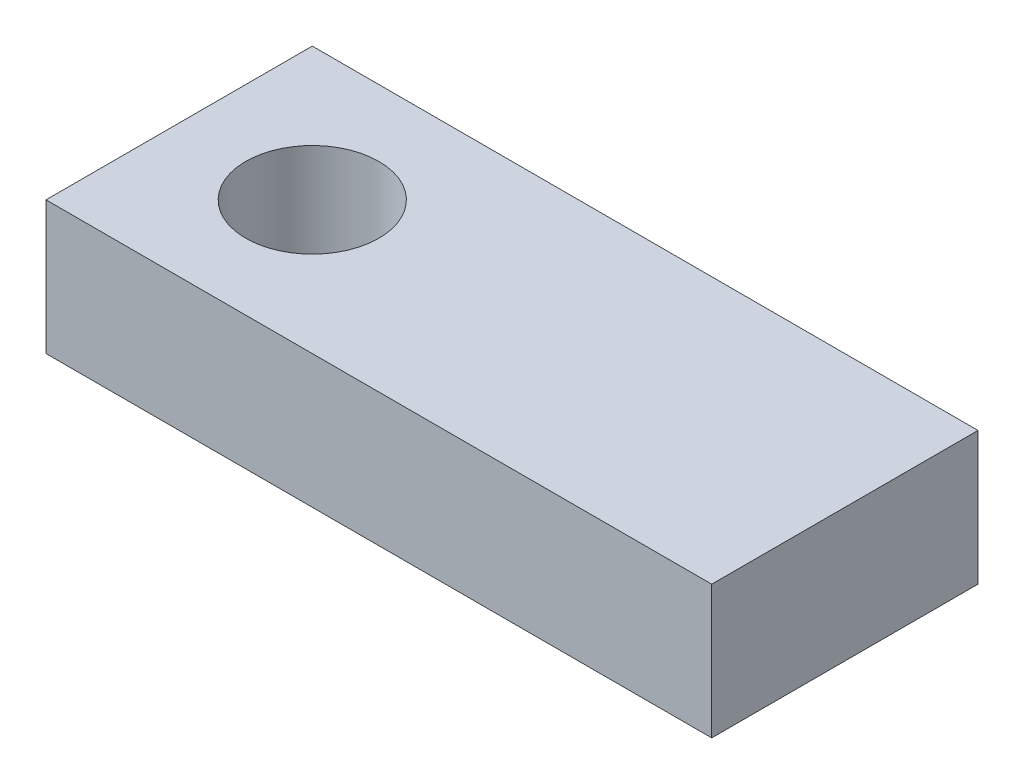
from build123d import *

# Parameters (mm, degrees)
SKETCH2_W           = 127
SKETCH2_H           = 50.8
BOSS_EXTRUDE2_DEPTH = 25.4
CUT_EXTRUDE1_REACH  = 27.4
SKETCH3_R           = 12.7


with BuildPart() as part:
    # Sketch2 → Boss-Extrude2 (new body)
    with BuildSketch(Plane(origin=(0, 0, 0), x_dir=(1, 0, 0), z_dir=(0, 1, 0))):
        with Locations((63.5, 25.4)):
            Rectangle(SKETCH2_W, SKETCH2_H)
    extrude(amount=BOSS_EXTRUDE2_DEPTH)

    # Sketch3 → Cut-Extrude1 (cut, up to next)
    with BuildSketch(Plane.XZ, mode=Mode.PRIVATE) as cut_extrude1_sk1:
        with Locations((25.4, -25.4)):
            Circle(SKETCH3_R)
    cut_extrude1_tool1 = extrude(cut_extrude1_sk1.sketch, amount=-CUT_EXTRUDE1_REACH, mode=Mode.PRIVATE) & part.part
    add(cut_extrude1_tool1.solids().sort_by_distance((25.4, 0, -25.4))[0], mode=Mode.SUBTRACT)


solid = part.part
